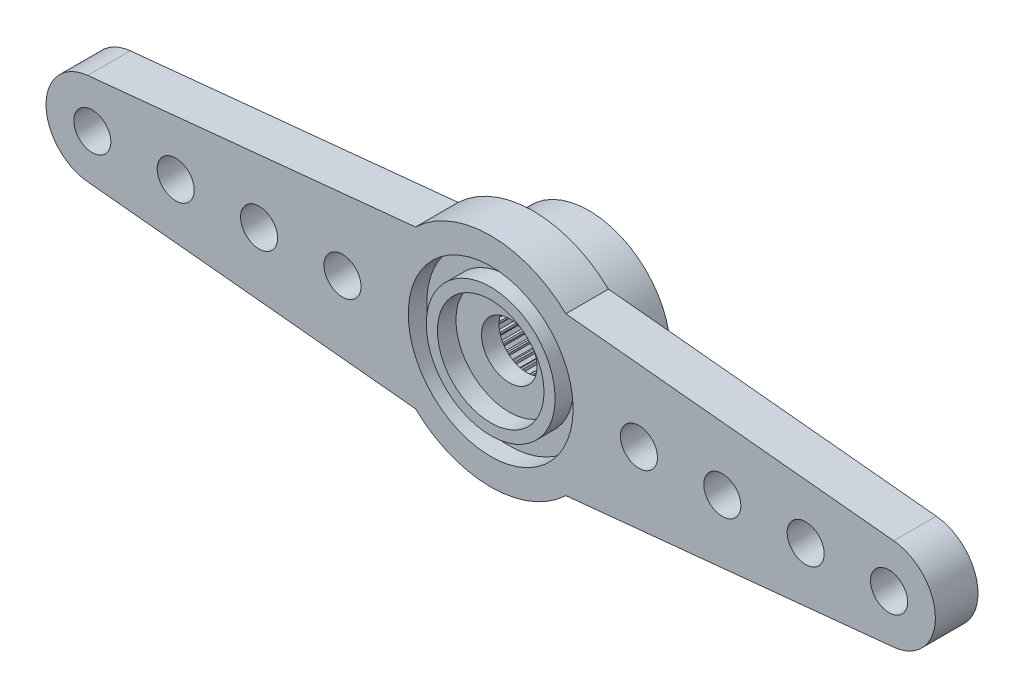
from build123d import *

# Parameters (mm, degrees)
BOSS_EXTRU_1_DEPTH      = 2.3
ESQUISSE2_R             = 4.45
ENL_V_MAT_EXTRU_1_DEPTH = 1
ESQUISSE3_R             = 3.475
ESQUISSE3_R_2           = 2.875
BOSS_EXTRU_2_DEPTH      = 1
ESQUISSE4_R             = 4.4
BOSS_EXTRU_3_DEPTH      = 3
ESQUISSE5_R             = 1.5
ENL_V_MAT_EXTRU_2_DEPTH = 5.3
ESQUISSE6_R             = 1.5
ENL_V_MAT_EXTRU_3_DEPTH = 3.35
ESQUISSE7_R             = 1
ENL_V_MAT_EXTRU_4_DEPTH = 3.35
SCALE2_SCALE            = 0.833333333


with BuildPart() as part:
    # Esquisse1 → Boss.-Extru.1 (new body)
    with BuildSketch(Plane.XY):
        with BuildLine():
            Line((-21.747806415, 2.487688079), (-4.056245185, 4.25))
            ThreePointArc((-4.056245185, 4.25), (0, 5.875), (4.056245185, 4.25))
            Line((4.056245185, 4.25), (21.747806415, 2.487688079))
            ThreePointArc((21.747806415, 2.487688079), (24, 0), (21.747806415, -2.487688079))
            Line((21.747806415, -2.487688079), (4.056245185, -4.25))
            ThreePointArc((4.056245185, -4.25), (0, -5.875), (-4.056245185, -4.25))
            Line((-4.056245185, -4.25), (-21.747806415, -2.487688079))
            ThreePointArc((-21.747806415, -2.487688079), (-24, 0), (-21.747806415, 2.487688079))
        make_face()
    extrude(amount=BOSS_EXTRU_1_DEPTH)

    # Esquisse2 → Enlèv. mat.-Extru.1 (cut)
    with BuildSketch(Plane.XY.offset(2.3)):
        Circle(ESQUISSE2_R)
    extrude(amount=-ENL_V_MAT_EXTRU_1_DEPTH, mode=Mode.SUBTRACT)

    # Esquisse3 → Boss.-Extru.2 (add)
    with BuildSketch(Plane.XY.offset(1.3)):
        Circle(ESQUISSE3_R)
        Circle(ESQUISSE3_R_2, mode=Mode.SUBTRACT)
    extrude(amount=BOSS_EXTRU_2_DEPTH)

    # Esquisse4 → Boss.-Extru.3 (add)
    with BuildSketch(Plane(origin=(0, 0, 0), x_dir=(-1, 0, 0), z_dir=(0, 0, -1))):
        Circle(ESQUISSE4_R)
    extrude(amount=BOSS_EXTRU_3_DEPTH)

    # Esquisse5 → Enlèv. mat.-Extru.2 (cut, through all)
    with BuildSketch(Plane.XY.offset(1.3)):
        Circle(ESQUISSE5_R)
    extrude(amount=-ENL_V_MAT_EXTRU_2_DEPTH, mode=Mode.SUBTRACT)

    # Esquisse6 → Enlèv. mat.-Extru.3 (cut)
    with BuildSketch(Plane(origin=(0, 0, -3), x_dir=(-1, 0, 0), z_dir=(0, 0, -1))):
        with BuildLine():
            Line((-0.040605305, 2.865160176), (-0.114276657, 2.997822684))
            ThreePointArc((-0.114276657, 2.997822684), (-0.209269421, 2.992692151), (-0.304051754, 2.984552317))
            Line((-0.304051754, 2.984552317), (-0.35854309, 2.8429278))
            Line((-0.35854309, 2.8429278), (-0.438963363, 2.831625467))
            Line((-0.438963363, 2.831625467), (-0.530380804, 2.952743843))
            ThreePointArc((-0.530380804, 2.952743843), (-0.623735072, 2.934442802), (-0.716462144, 2.913191033))
            Line((-0.716462144, 2.913191033), (-0.750712851, 2.765361068))
            Line((-0.750712851, 2.765361068), (-0.828777499, 2.742976391))
            Line((-0.828777499, 2.742976391), (-0.936161691, 2.850193202))
            ThreePointArc((-0.936161691, 2.850193202), (-1.02606043, 2.819077862), (-1.114927414, 2.7851278))
            Line((-1.114927414, 2.7851278), (-1.12827084, 2.633969729))
            Line((-1.12827084, 2.633969729), (-1.202460424, 2.600938398))
            Line((-1.202460424, 2.600938398), (-1.323721256, 2.692166792))
            ThreePointArc((-1.323721256, 2.692166792), (-1.408414688, 2.648842779), (-1.491691889, 2.602855222))
            Line((-1.491691889, 2.602855222), (-1.483868321, 2.451311165))
            Line((-1.483868321, 2.451311165), (-1.552738824, 2.408276099))
            Line((-1.552738824, 2.408276099), (-1.685516093, 2.481740418))
            ThreePointArc((-1.685516093, 2.481740418), (-1.763355757, 2.427050983), (-1.839422279, 2.369921028))
            Line((-1.839422279, 2.369921028), (-1.810583992, 2.220940618))
            Line((-1.810583992, 2.220940618), (-1.872794929, 2.168739444))
            Line((-1.872794929, 2.168739444), (-2.014504276, 2.223009789))
            ThreePointArc((-2.014504276, 2.223009789), (-2.083975111, 2.158019401), (-2.151350406, 2.090859017))
            Line((-2.151350406, 2.090859017), (-2.102058706, 1.947341988))
            Line((-2.102058706, 1.947341988), (-2.156399211, 1.886990743))
            Line((-2.156399211, 1.886990743), (-2.304282424, 1.921010804))
            ThreePointArc((-2.304282424, 1.921010804), (-2.364032261, 1.846984426), (-2.421404945, 1.771100813))
            Line((-2.421404945, 1.771100813), (-2.352619239, 1.635840561))
            Line((-2.352619239, 1.635840561), (-2.398031635, 1.568513914))
            Line((-2.398031635, 1.568513914), (-2.549210337, 1.581621528))
            ThreePointArc((-2.549210337, 1.581621528), (-2.598076211, 1.5), (-2.644329591, 1.416870147))
            Line((-2.644329591, 1.416870147), (-2.557388713, 1.292499358))
            Line((-2.557388713, 1.292499358), (-2.592989102, 1.219507746))
            Line((-2.592989102, 1.219507746), (-2.74452077, 1.211447789))
            ThreePointArc((-2.74452077, 1.211447789), (-2.781551564, 1.12381978), (-2.815785369, 1.035061715))
            Line((-2.815785369, 1.035061715), (-2.712381526, 0.924001126))
            Line((-2.712381526, 0.924001126), (-2.737476984, 0.846765246))
            Line((-2.737476984, 0.846765246), (-2.886412228, 0.817694596))
            ThreePointArc((-2.886412228, 0.817694596), (-2.910887179, 0.725765687), (-2.932435088, 0.633106984))
            Line((-2.932435088, 0.633106984), (-2.814580917, 0.537518262))
            Line((-2.814580917, 0.537518262), (-2.828682992, 0.457541424))
            Line((-2.828682992, 0.457541424), (-2.972122955, 0.408025908))
            ThreePointArc((-2.972122955, 0.408025908), (-2.983565686, 0.31358539), (-2.992008294, 0.218829546))
            Line((-2.992008294, 0.218829546), (-2.861997693, 0.140573217))
            Line((-2.861997693, 0.140573217), (-2.864831902, 0.059412079))
            Line((-2.864831902, 0.059412079), (-2.999984689, -0.00958454))
            ThreePointArc((-2.999984689, -0.00958454), (-2.998172481, -0.10469849), (-2.993345461, -0.19970716))
            Line((-2.993345461, -0.19970716), (-2.853708938, -0.259107925))
            Line((-2.853708938, -0.259107925), (-2.845220118, -0.339873655))
            Line((-2.845220118, -0.339873655), (-2.969455134, -0.427008436))
            ThreePointArc((-2.969455134, -0.427008436), (-2.954423259, -0.520944533), (-2.936420564, -0.614356794))
            Line((-2.936420564, -0.614356794), (-2.789875986, -0.653745827))
            Line((-2.789875986, -0.653745827), (-2.770229361, -0.732544135))
            Line((-2.770229361, -0.732544135), (-2.881128513, -0.836121099))
            ThreePointArc((-2.881128513, -0.836121099), (-2.853169549, -0.927050983), (-2.822341581, -1.017048672))
            Line((-2.822341581, -1.017048672), (-2.67174127, -1.03565931))
            Line((-2.67174127, -1.03565931), (-2.641319241, -1.110956476))
            Line((-2.641319241, -1.110956476), (-2.736724002, -1.228959615))
            ThreePointArc((-2.736724002, -1.228959615), (-2.696382139, -1.31511344), (-2.653328929, -1.399944854))
            Line((-2.653328929, -1.399944854), (-2.50160415, -1.397414862))
            Line((-2.50160415, -1.397414862), (-2.460998845, -1.467745313))
            Line((-2.460998845, -1.467745313), (-2.539052272, -1.59787783))
            ThreePointArc((-2.539052272, -1.59787783), (-2.487112718, -1.67757871), (-2.432672248, -1.755592702))
            Line((-2.432672248, -1.755592702), (-2.282776151, -1.731971324))
            Line((-2.282776151, -1.731971324), (-2.232777907, -1.795966158))
            Line((-2.232777907, -1.795966158), (-2.291960777, -1.935695171))
            ThreePointArc((-2.291960777, -1.935695171), (-2.229434476, -2.007391819), (-2.164666369, -2.077069935))
            Line((-2.164666369, -2.077069935), (-2.019516511, -2.032816934))
            Line((-2.019516511, -2.032816934), (-1.961098487, -2.089230564))
            Line((-1.961098487, -2.089230564), (-2.000258873, -2.235836408))
            ThreePointArc((-2.000258873, -2.235836408), (-1.928362829, -2.298133329), (-1.854527721, -2.358119364))
            Line((-1.854527721, -2.358119364), (-1.716949278, -2.294096074))
            Line((-1.716949278, -2.294096074), (-1.651248515, -2.341830473))
            Line((-1.651248515, -2.341830473), (-1.669624205, -2.492459631))
            ThreePointArc((-1.669624205, -2.492459631), (-1.589757793, -2.544144288), (-1.5082928, -2.593270682))
            Line((-1.5082928, -2.593270682), (-1.380963581, -2.510723244))
            Line((-1.380963581, -2.510723244), (-1.309258869, -2.548849316))
            Line((-1.309258869, -2.548849316), (-1.306492201, -2.700569964))
            ThreePointArc((-1.306492201, -2.700569964), (-1.220209929, -2.740636373), (-1.132700676, -2.777946936))
            Line((-1.132700676, -2.777946936), (-1.018098999, -2.678482042))
            Line((-1.018098999, -2.678482042), (-0.941785989, -2.706257707))
            Line((-0.941785989, -2.706257707), (-0.917930812, -2.856116773))
            ThreePointArc((-0.917930812, -2.856116773), (-0.826912067, -2.883785088), (-0.735061821, -2.908553613))
            Line((-0.735061821, -2.908553613), (-0.635418278, -2.794107234))
            Line((-0.635418278, -2.794107234), (-0.555982315, -2.810991869))
            Line((-0.555982315, -2.810991869), (-0.511502945, -2.956072519))
            ThreePointArc((-0.511502945, -2.956072519), (-0.417519303, -2.970804206), (-0.323115824, -2.982548602))
            Line((-0.323115824, -2.982548602), (-0.240369863, -2.855348306))
            Line((-0.240369863, -2.855348306), (-0.159357078, -2.861013272))
            Line((-0.159357078, -2.861013272), (-0.095119254, -2.998491675))
            ThreePointArc((-0.095119254, -2.998491675), (0, -3), (0.095119254, -2.998491675))
            Line((0.095119254, -2.998491675), (0.159357078, -2.861013272))
            Line((0.159357078, -2.861013272), (0.240369863, -2.855348306))
            Line((0.240369863, -2.855348306), (0.323115824, -2.982548602))
            ThreePointArc((0.323115824, -2.982548602), (0.417519303, -2.970804206), (0.511502945, -2.956072519))
            Line((0.511502945, -2.956072519), (0.555982315, -2.810991869))
            Line((0.555982315, -2.810991869), (0.635418278, -2.794107234))
            Line((0.635418278, -2.794107234), (0.735061821, -2.908553613))
            ThreePointArc((0.735061821, -2.908553613), (0.826912067, -2.883785088), (0.917930812, -2.856116773))
            Line((0.917930812, -2.856116773), (0.941785989, -2.706257707))
            Line((0.941785989, -2.706257707), (1.018098999, -2.678482042))
            Line((1.018098999, -2.678482042), (1.132700676, -2.777946936))
            ThreePointArc((1.132700676, -2.777946936), (1.220209929, -2.740636373), (1.306492201, -2.700569964))
            Line((1.306492201, -2.700569964), (1.309258869, -2.548849316))
            Line((1.309258869, -2.548849316), (1.380963581, -2.510723244))
            Line((1.380963581, -2.510723244), (1.5082928, -2.593270682))
            ThreePointArc((1.5082928, -2.593270682), (1.589757793, -2.544144288), (1.669624205, -2.492459631))
            Line((1.669624205, -2.492459631), (1.651248515, -2.341830473))
            Line((1.651248515, -2.341830473), (1.716949278, -2.294096074))
            Line((1.716949278, -2.294096074), (1.854527721, -2.358119364))
            ThreePointArc((1.854527721, -2.358119364), (1.928362829, -2.298133329), (2.000258873, -2.235836408))
            Line((2.000258873, -2.235836408), (1.961098487, -2.089230564))
            Line((1.961098487, -2.089230564), (2.019516511, -2.032816934))
            Line((2.019516511, -2.032816934), (2.164666369, -2.077069935))
            ThreePointArc((2.164666369, -2.077069935), (2.229434476, -2.007391819), (2.291960777, -1.935695171))
            Line((2.291960777, -1.935695171), (2.232777907, -1.795966158))
            Line((2.232777907, -1.795966158), (2.282776151, -1.731971324))
            Line((2.282776151, -1.731971324), (2.432672248, -1.755592702))
            ThreePointArc((2.432672248, -1.755592702), (2.487112718, -1.67757871), (2.539052272, -1.59787783))
            Line((2.539052272, -1.59787783), (2.460998845, -1.467745313))
            Line((2.460998845, -1.467745313), (2.50160415, -1.397414862))
            Line((2.50160415, -1.397414862), (2.653328929, -1.399944854))
            ThreePointArc((2.653328929, -1.399944854), (2.696382139, -1.31511344), (2.736724002, -1.228959615))
            Line((2.736724002, -1.228959615), (2.641319241, -1.110956476))
            Line((2.641319241, -1.110956476), (2.67174127, -1.03565931))
            Line((2.67174127, -1.03565931), (2.822341581, -1.017048672))
            ThreePointArc((2.822341581, -1.017048672), (2.853169549, -0.927050983), (2.881128513, -0.836121099))
            Line((2.881128513, -0.836121099), (2.770229361, -0.732544135))
            Line((2.770229361, -0.732544135), (2.789875986, -0.653745827))
            Line((2.789875986, -0.653745827), (2.936420564, -0.614356794))
            ThreePointArc((2.936420564, -0.614356794), (2.954423259, -0.520944533), (2.969455134, -0.427008436))
            Line((2.969455134, -0.427008436), (2.845220118, -0.339873655))
            Line((2.845220118, -0.339873655), (2.853708938, -0.259107925))
            Line((2.853708938, -0.259107925), (2.993345461, -0.19970716))
            ThreePointArc((2.993345461, -0.19970716), (2.998172481, -0.10469849), (2.999984689, -0.00958454))
            Line((2.999984689, -0.00958454), (2.864831902, 0.059412079))
            Line((2.864831902, 0.059412079), (2.861997693, 0.140573217))
            Line((2.861997693, 0.140573217), (2.992008294, 0.218829546))
            ThreePointArc((2.992008294, 0.218829546), (2.983565686, 0.31358539), (2.972122955, 0.408025908))
            Line((2.972122955, 0.408025908), (2.828682992, 0.457541424))
            Line((2.828682992, 0.457541424), (2.814580917, 0.537518262))
            Line((2.814580917, 0.537518262), (2.932435088, 0.633106984))
            ThreePointArc((2.932435088, 0.633106984), (2.910887179, 0.725765687), (2.886412228, 0.817694596))
            Line((2.886412228, 0.817694596), (2.737476984, 0.846765246))
            Line((2.737476984, 0.846765246), (2.712381526, 0.924001126))
            Line((2.712381526, 0.924001126), (2.815785369, 1.035061715))
            ThreePointArc((2.815785369, 1.035061715), (2.781551564, 1.12381978), (2.74452077, 1.211447789))
            Line((2.74452077, 1.211447789), (2.592989102, 1.219507746))
            Line((2.592989102, 1.219507746), (2.557388713, 1.292499358))
            Line((2.557388713, 1.292499358), (2.644329591, 1.416870147))
            ThreePointArc((2.644329591, 1.416870147), (2.598076211, 1.5), (2.549210337, 1.581621528))
            Line((2.549210337, 1.581621528), (2.398031635, 1.568513914))
            Line((2.398031635, 1.568513914), (2.352619239, 1.635840561))
            Line((2.352619239, 1.635840561), (2.421404945, 1.771100813))
            ThreePointArc((2.421404945, 1.771100813), (2.364032261, 1.846984426), (2.304282424, 1.921010804))
            Line((2.304282424, 1.921010804), (2.156399211, 1.886990743))
            Line((2.156399211, 1.886990743), (2.102058706, 1.947341988))
            Line((2.102058706, 1.947341988), (2.151350406, 2.090859017))
            ThreePointArc((2.151350406, 2.090859017), (2.083975111, 2.158019401), (2.014504276, 2.223009789))
            Line((2.014504276, 2.223009789), (1.872794929, 2.168739444))
            Line((1.872794929, 2.168739444), (1.810583992, 2.220940618))
            Line((1.810583992, 2.220940618), (1.839422279, 2.369921028))
            ThreePointArc((1.839422279, 2.369921028), (1.763355757, 2.427050983), (1.685516093, 2.481740418))
            Line((1.685516093, 2.481740418), (1.552738824, 2.408276099))
            Line((1.552738824, 2.408276099), (1.483868321, 2.451311165))
            Line((1.483868321, 2.451311165), (1.491691889, 2.602855222))
            ThreePointArc((1.491691889, 2.602855222), (1.408414688, 2.648842779), (1.323721256, 2.692166792))
            Line((1.323721256, 2.692166792), (1.202460424, 2.600938398))
            Line((1.202460424, 2.600938398), (1.12827084, 2.633969729))
            Line((1.12827084, 2.633969729), (1.114927414, 2.7851278))
            ThreePointArc((1.114927414, 2.7851278), (1.02606043, 2.819077862), (0.936161691, 2.850193202))
            Line((0.936161691, 2.850193202), (0.828777499, 2.742976391))
            Line((0.828777499, 2.742976391), (0.750712851, 2.765361068))
            Line((0.750712851, 2.765361068), (0.716462144, 2.913191033))
            ThreePointArc((0.716462144, 2.913191033), (0.623735072, 2.934442802), (0.530380804, 2.952743843))
            Line((0.530380804, 2.952743843), (0.438963363, 2.831625467))
            Line((0.438963363, 2.831625467), (0.35854309, 2.8429278))
            Line((0.35854309, 2.8429278), (0.304051754, 2.984552317))
            ThreePointArc((0.304051754, 2.984552317), (0.209269421, 2.992692151), (0.114276657, 2.997822684))
            Line((0.114276657, 2.997822684), (0.040605305, 2.865160176))
            Line((0.040605305, 2.865160176), (-0.040605305, 2.865160176))
        make_face()
        Circle(ESQUISSE6_R, mode=Mode.SUBTRACT)
    extrude(amount=-ENL_V_MAT_EXTRU_3_DEPTH, mode=Mode.SUBTRACT)

    # Esquisse7 → Enlèv. mat.-Extru.4 (cut)
    with BuildSketch(Plane.XY.offset(2.3)):
        with Locations((-21.5, 0)):
            Circle(ESQUISSE7_R)
        with Locations((-17, 0)):
            Circle(ESQUISSE7_R)
        with Locations((-12.5, 0)):
            Circle(ESQUISSE7_R)
        with Locations((-8, 0)):
            Circle(ESQUISSE7_R)
        with Locations((8, 0)):
            Circle(ESQUISSE7_R)
        with Locations((12.5, 0)):
            Circle(ESQUISSE7_R)
        with Locations((17, 0)):
            Circle(ESQUISSE7_R)
        with Locations((21.5, 0)):
            Circle(ESQUISSE7_R)
    extrude(amount=-ENL_V_MAT_EXTRU_4_DEPTH, mode=Mode.SUBTRACT)


with BuildPart() as part_1:
    # Scale2: scaled about (0, 0, 0.773975727)
    add(part.part.scale(SCALE2_SCALE).moved(Location((0, 0, 0.128995954))))


solid = part_1.part
